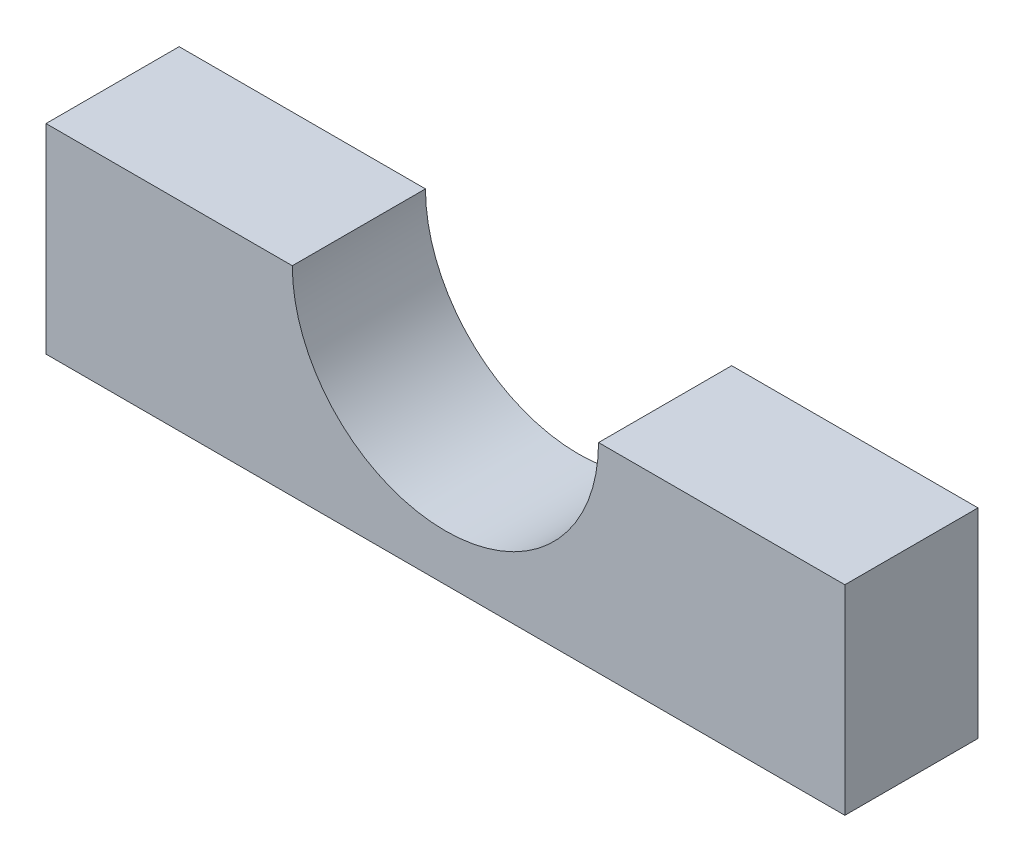
from build123d import *

# Parameters (mm, degrees)
BOSS_EXTRUDE1_DEPTH = 12.7


with BuildPart() as part:
    # Sketch1 → Boss-Extrude1 (new body)
    with BuildSketch(Plane.XY):
        with BuildLine():
            Line((-38.1, -19.05), (38.1, -19.05))
            Line((38.1, -19.05), (38.1, 0))
            Line((38.1, 0), (14.605, 0))
            ThreePointArc((14.605, 0), (0, -14.605), (-14.605, 0))
            Line((-14.605, 0), (-38.1, 0))
            Line((-38.1, 0), (-38.1, -19.05))
        make_face()
    extrude(amount=BOSS_EXTRUDE1_DEPTH)


solid = part.part
